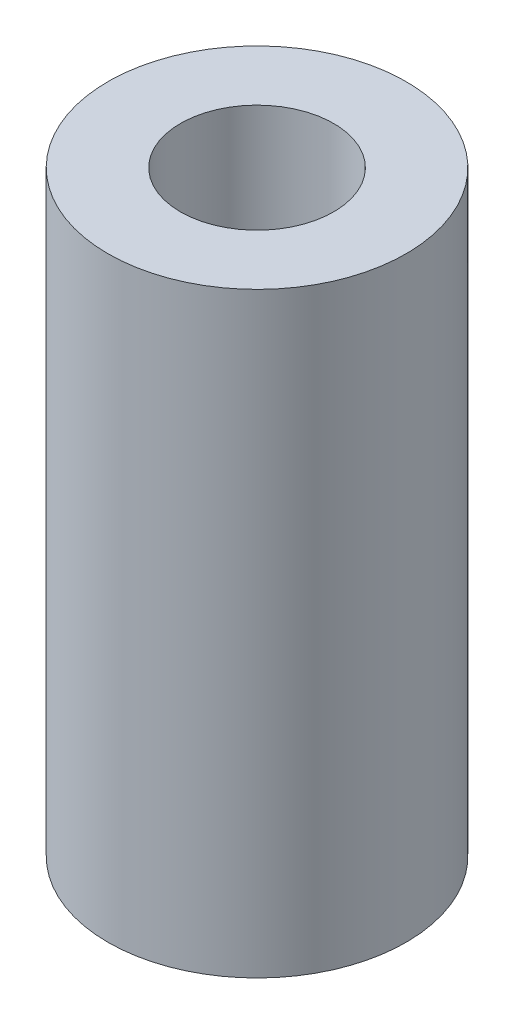
from build123d import *

# Parameters (mm, degrees)
SKETCH1_R           = 6.35
SKETCH1_R_2         = 3.2639
BOSS_EXTRUDE1_DEPTH = 25.4


with BuildPart() as part:
    # Sketch1 → Boss-Extrude1 (new body)
    with BuildSketch(Plane(origin=(0, 0, 0), x_dir=(1, 0, 0), z_dir=(0, 1, 0))):
        Circle(SKETCH1_R)
        Circle(SKETCH1_R_2, mode=Mode.SUBTRACT)
    extrude(amount=BOSS_EXTRUDE1_DEPTH)


solid = part.part
